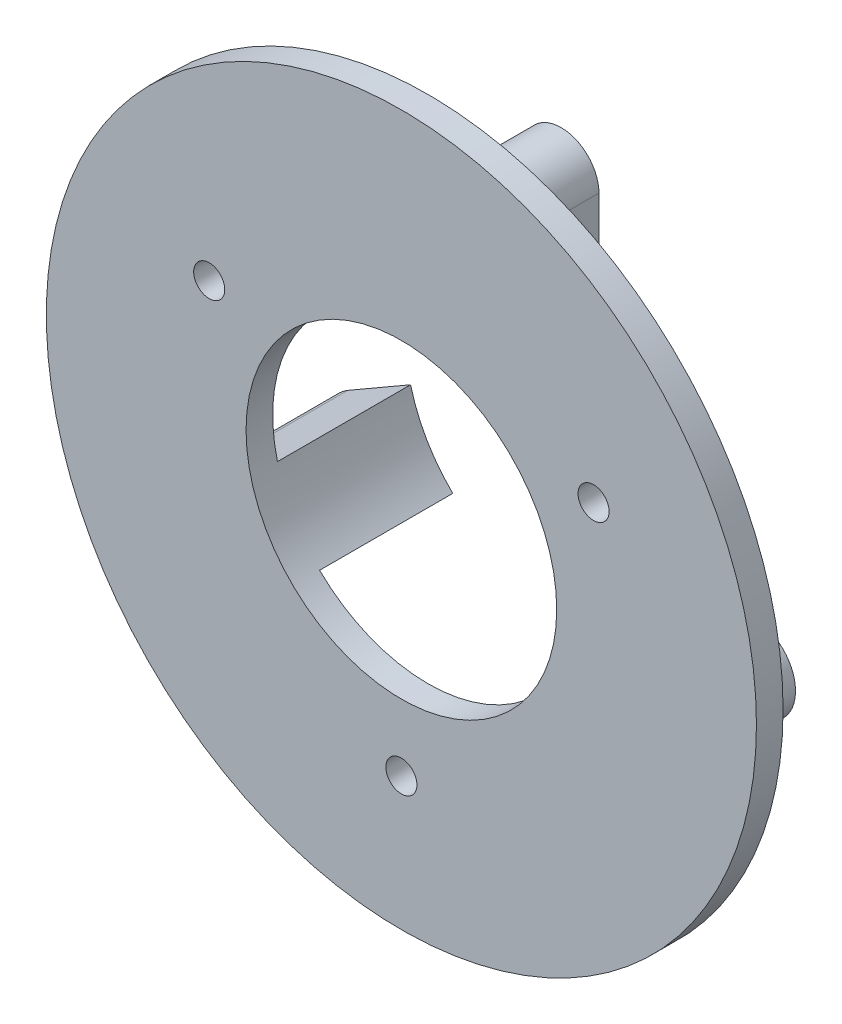
from build123d import *

# Parameters (mm, degrees)
SKETCH_1_R          = 16
EXTRUDE_1_DEPTH     = 1.2
SKETCH_2_R          = 7
CUT_EXTRUDE_1_DEPTH = 1.2
SKETCH_3_R          = 0.7
CUT_EXTRUDE_2_DEPTH = 1.2
SKETCH_4_R          = 0.9
EXTRUDE_2_DEPTH     = 6
SKETCH_5_R          = 7
CUT_EXTRUDE_3_DEPTH = 11


with BuildPart() as part:
    # 草图1 → 凸台-拉伸1 (new body)
    with BuildSketch(Plane.XY):
        Circle(SKETCH_1_R)
    extrude(amount=EXTRUDE_1_DEPTH)

    # 草图2 → 切除-拉伸1 (cut)
    with BuildSketch(Plane.XY.offset(1.2)):
        Circle(SKETCH_2_R)
    extrude(amount=-CUT_EXTRUDE_1_DEPTH, mode=Mode.SUBTRACT)

    # 草图3 → 切除-拉伸2 (cut)
    with BuildSketch(Plane.XY.offset(1.2)):
        with Locations((8.660254038, 5)):
            Circle(SKETCH_3_R)
        with Locations((0, -10)):
            Circle(SKETCH_3_R)
        with Locations((-8.660254038, 5)):
            Circle(SKETCH_3_R)
    extrude(amount=-CUT_EXTRUDE_2_DEPTH, mode=Mode.SUBTRACT)

    # 草图4 → 凸台-拉伸2 (add)
    with BuildSketch(Plane(origin=(0, 0, 0), x_dir=(-1, 0, 0), z_dir=(0, 0, -1))):
        with BuildLine():
            Line((1.703894623, 10), (1.703894623, 5.395195442))
            Line((1.703894623, 5.395195442), (-1.703894623, 5.395195442))
            Line((-1.703894623, 5.395195442), (-1.703894623, 10))
            ThreePointArc((-1.703894623, 10), (0, 11.703894623), (1.703894623, 10))
        make_face()
        with Locations((0, 10)):
            Circle(SKETCH_4_R, mode=Mode.SUBTRACT)
        with BuildLine():
            Line((-5.537946003, -1.003403593), (-3.637946003, -4.294300127))
            Line((-3.637946003, -4.294300127), (-7.710254038, -6.645448267))
            ThreePointArc((-7.710254038, -6.645448267), (-10.305702305, -5.95), (-9.610254038, -3.354551733))
            Line((-9.610254038, -3.354551733), (-5.537946003, -1.003403593))
        make_face()
        with Locations((-8.660254038, -5)):
            Circle(SKETCH_4_R, mode=Mode.SUBTRACT)
        with BuildLine():
            Line((3.637946003, -4.294300127), (5.537946003, -1.003403593))
            Line((5.537946003, -1.003403593), (9.610254038, -3.354551733))
            ThreePointArc((9.610254038, -3.354551733), (10.305702305, -5.95), (7.710254038, -6.645448267))
            Line((7.710254038, -6.645448267), (3.637946003, -4.294300127))
        make_face()
        with Locations((8.660254038, -5)):
            Circle(SKETCH_4_R, mode=Mode.SUBTRACT)
    extrude(amount=EXTRUDE_2_DEPTH)

    # 草图5 → 切除-拉伸3 (cut)
    with BuildSketch(Plane.XY.offset(1.2)):
        Circle(SKETCH_5_R)
    extrude(amount=-CUT_EXTRUDE_3_DEPTH, mode=Mode.SUBTRACT)


solid = part.part
